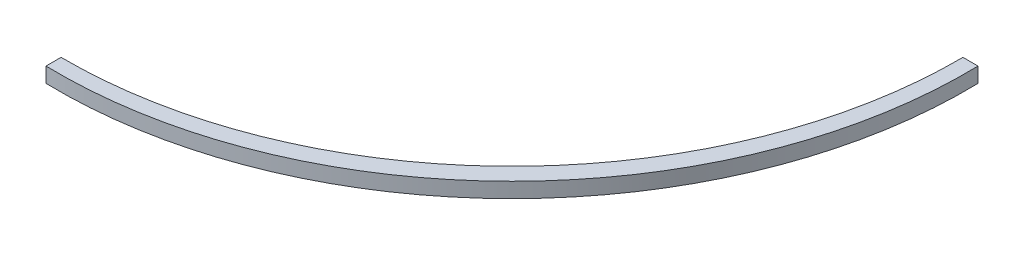
from build123d import *

# Parameters (mm, degrees)
RESSALTO_EXTRUS_O1_DEPTH = 40


with BuildPart() as part:
    # Esboço1 → Ressalto-extrusão1 (new body)
    with BuildSketch(Plane(origin=(0, 0, 0), x_dir=(1, 0, 0), z_dir=(0, 1, 0))):
        with BuildLine():
            Line((0, -40), (0, 0))
            ThreePointArc((0, 0), (850.258814768, 348.510379221), (1198.769193989, 1198.769193989))
            Line((1198.769193989, 1198.769193989), (1238.769193989, 1198.769193989))
            ThreePointArc((1238.769193989, 1198.769193989), (884.718843923, 314.050350066), (0, -40))
        make_face()
    extrude(amount=RESSALTO_EXTRUS_O1_DEPTH)


solid = part.part
